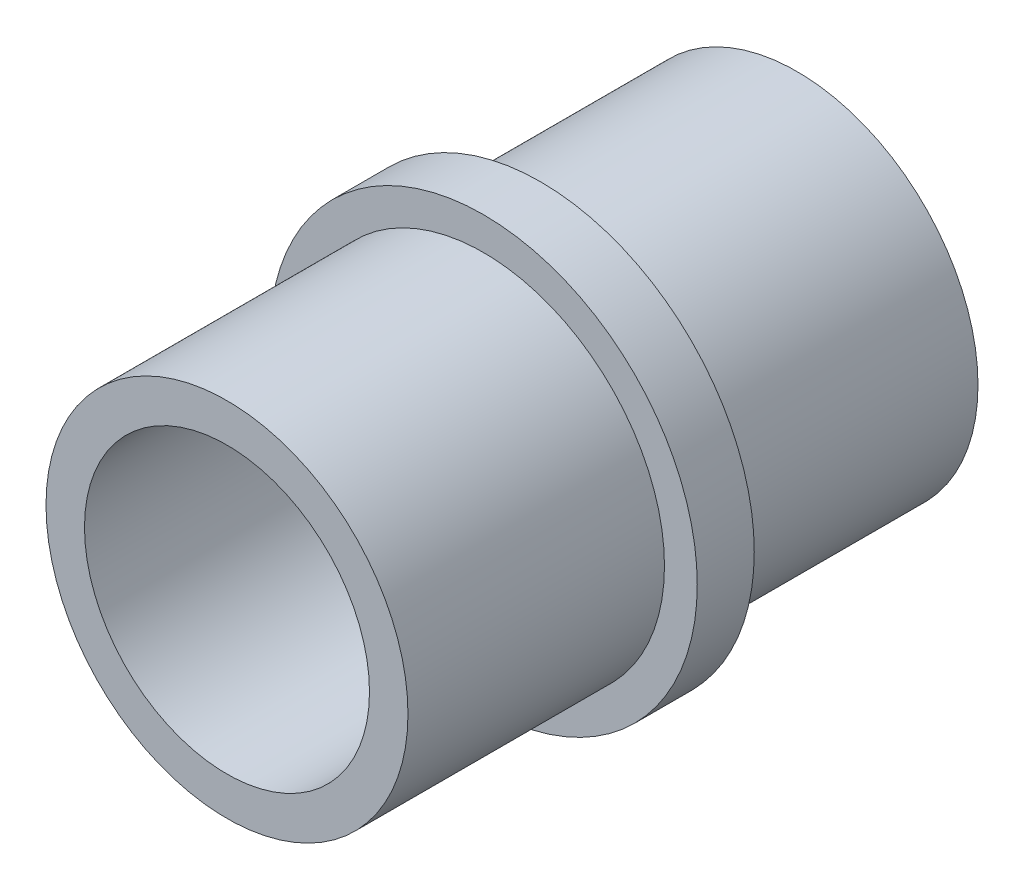
from build123d import *

# Parameters (mm, degrees)
SKETCH1_R           = 6.35
SKETCH1_R_2         = 5
BOSS_EXTRUDE1_DEPTH = 10
SKETCH2_R           = 7.5
SKETCH2_R_2         = 6.35
BOSS_EXTRUDE2_DEPTH = 1


with BuildPart() as part:
    # Sketch1 → Boss-Extrude1 (new body, symmetric)
    with BuildSketch(Plane.XY):
        Circle(SKETCH1_R)
        Circle(SKETCH1_R_2, mode=Mode.SUBTRACT)
    extrude(amount=BOSS_EXTRUDE1_DEPTH, both=True)

    # Sketch2 → Boss-Extrude2 (add, symmetric)
    with BuildSketch(Plane.XY):
        Circle(SKETCH2_R)
        Circle(SKETCH2_R_2, mode=Mode.SUBTRACT)
    extrude(amount=BOSS_EXTRUDE2_DEPTH, both=True)


solid = part.part
